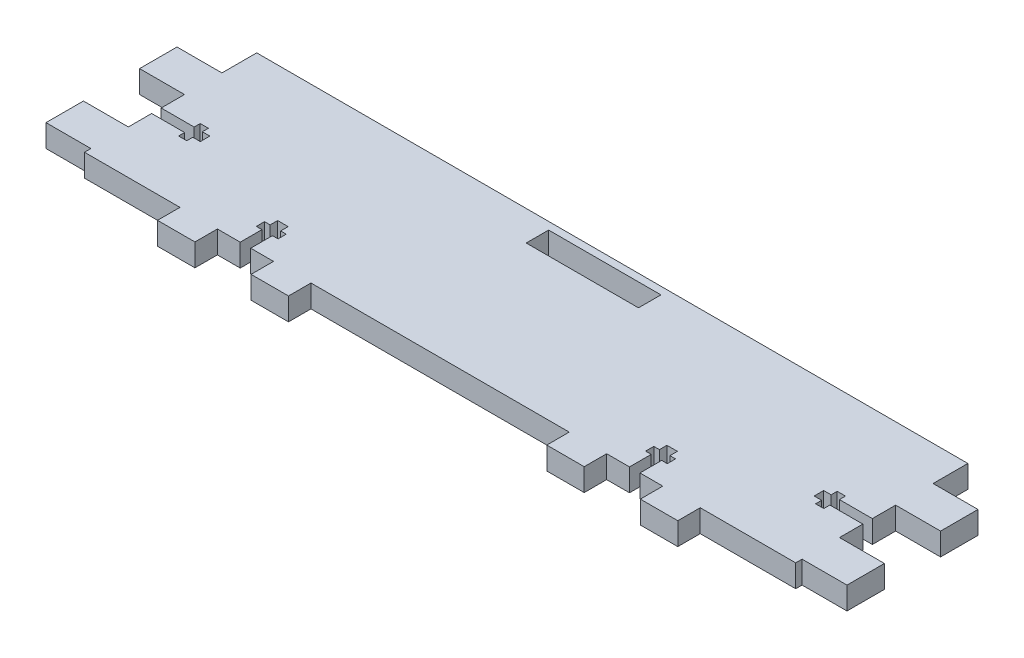
from build123d import *

# Parameters (mm, degrees)
SKETCH_1_W      = 30
SKETCH_1_H      = 6
EXTRUDE_1_DEPTH = 6


with BuildPart() as part:
    # Эскиз1 → Бобышка-Вытянуть1 (new body)
    with BuildSketch(Plane(origin=(0, 0, 0), x_dir=(1, 0, 0), z_dir=(0, 1, 0))):
        Polygon((-95, 23), (95, 23), (95, 13.709265489), (107, 13.709265489), (107, 3.709265489), (95, 3.709265489), (95, -2.518957871), (86.2, -2.518957871), (86.2, -0.901182203), (84, -0.901182203), (84, -2.518957871), (82, -2.518957871), (82, -5.062511151), (84, -5.062511151), (84, -6.68028682), (86.2, -6.68028682), (86.2, -5.062511151), (95, -5.062511151), (95, -11.290734511), (107, -11.290734511), (107, -21.290734511), (95, -21.290734511), (95, -23), (69.5, -23), (69.5, -29), (59.5, -29), (59.5, -23), (53.4, -23), (53.4, -17.2), (54.9, -17.2), (54.9, -15), (53.4, -15), (53.4, -13), (50.6, -13), (50.6, -15), (49.1, -15), (49.1, -17.2), (50.6, -17.2), (50.6, -23), (44.5, -23), (44.5, -29), (34.5, -29), (34.5, -23), (-34.5, -23), (-34.5, -29), (-44.5, -29), (-44.5, -23), (-50.6, -23), (-50.6, -17.2), (-49.1, -17.2), (-49.1, -15), (-50.6, -15), (-50.6, -13), (-53.4, -13), (-53.4, -15), (-54.9, -15), (-54.9, -17.2), (-53.4, -17.2), (-53.4, -23), (-59.5, -23), (-59.5, -29), (-69.5, -29), (-69.5, -23), (-95, -23), (-95, -21.290734511), (-107, -21.290734511), (-107, -11.290734511), (-95, -11.290734511), (-95, -5.062511151), (-86.2, -5.062511151), (-86.2, -6.68028682), (-84, -6.68028682), (-84, -5.062511151), (-82, -5.062511151), (-82, -2.518957871), (-84, -2.518957871), (-84, -0.901182203), (-86.2, -0.901182203), (-86.2, -2.518957871), (-95, -2.518957871), (-95, 3.709265489), (-107, 3.709265489), (-107, 13.709265489), (-95, 13.709265489), align=None)
        with Locations((0, 18)):
            Rectangle(SKETCH_1_W, SKETCH_1_H, mode=Mode.SUBTRACT)
    extrude(amount=EXTRUDE_1_DEPTH)


solid = part.part
